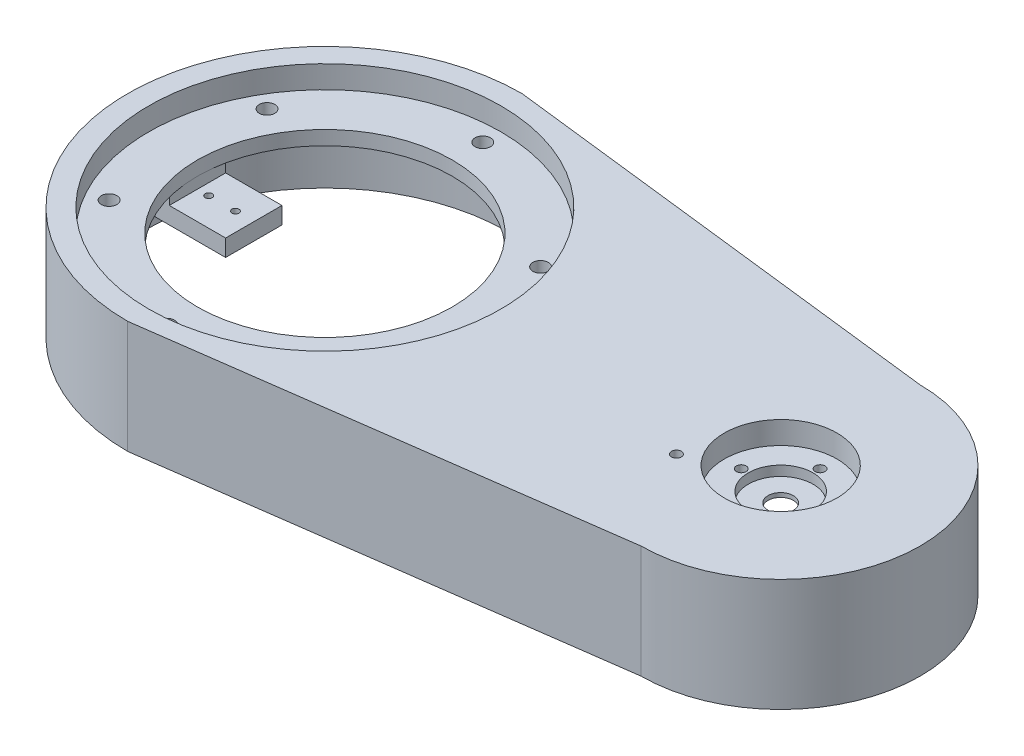
from build123d import *

# Parameters (mm, degrees)
BOSS_EXTRUDE1_DEPTH = 40
SKETCH2_R           = 45.22
SKETCH2_R_2         = 2.75
CUT_EXTRUDE1_DEPTH  = 28
SKETCH4_R           = 62.5
CUT_EXTRUDE2_DEPTH  = 8
CUT_EXTRUDE3_DEPTH  = 27
SKETCH6_R           = 1.75
SKETCH6_R_2         = 4.5
CUT_EXTRUDE4_DEPTH  = 23
SKETCH6_3_R         = 11.5
SKETCH6_3_R_2       = 4.5
CUT_EXTRUDE5_DEPTH  = 11.5
BOSS_EXTRUDE2_DEPTH = 10
SKETCH8_W           = 20
SKETCH8_H           = 6
BOSS_EXTRUDE3_DEPTH = 20
SKETCH9_R           = 1.25
CUT_EXTRUDE6_DEPTH  = 20
SKETCH6_4_R         = 20
SKETCH6_4_R_2       = 1.75
SKETCH6_4_R_3       = 4.5
CUT_EXTRUDE7_DEPTH  = 8
CUT_EXTRUDE8_START  = -168
SKETCH11_R          = 4.5
SKETCH11_R_2        = 1.75
CUT_EXTRUDE8_DEPTH  = 168


with BuildPart() as part:
    # Sketch1 → Boss-Extrude1 (new body)
    with BuildSketch(Plane(origin=(0, 0, 0), x_dir=(1, 0, 0), z_dir=(0, 1, 0))):
        with BuildLine():
            Line((0, 70), (160.2226, 51.102080384))
            ThreePointArc((160.2226, 51.102080384), (209.74985375, 1.574826635), (160.2226, -47.952427115))
            Line((160.2226, -47.952427115), (0, -70))
            ThreePointArc((0, -70), (-70, 0), (0, 70))
        make_face()
    extrude(amount=BOSS_EXTRUDE1_DEPTH)

    # Sketch2 → Cut-Extrude1 (cut)
    with BuildSketch(Plane(origin=(0, 40, 0), x_dir=(1, 0, 0), z_dir=(0, 1, 0))):
        Circle(SKETCH2_R)
        with Locations((0, 56.06)):
            Circle(SKETCH2_R_2)
        with Locations((-48.549384136, 28.03)):
            Circle(SKETCH2_R_2)
        with Locations((-48.549384136, -28.03)):
            Circle(SKETCH2_R_2)
        with Locations((0, -56.06)):
            Circle(SKETCH2_R_2)
        with Locations((48.549384136, -28.03)):
            Circle(SKETCH2_R_2)
        with Locations((48.549384136, 28.03)):
            Circle(SKETCH2_R_2)
    extrude(amount=-CUT_EXTRUDE1_DEPTH, mode=Mode.SUBTRACT)

    # Sketch4 → Cut-Extrude2 (cut)
    with BuildSketch(Plane(origin=(0, 40, 0), x_dir=(1, 0, 0), z_dir=(0, 1, 0))):
        Circle(SKETCH4_R)
    extrude(amount=-CUT_EXTRUDE2_DEPTH, mode=Mode.SUBTRACT)

    # Sketch5 → Cut-Extrude3 (cut)
    with BuildSketch(Plane.XZ):
        with BuildLine():
            Line((160.2226, 42.955173365), (0, 65))
            ThreePointArc((0, 65), (-65, 0), (0, -65))
            Line((0, -65), (160.2226, -46.104826635))
            ThreePointArc((160.2226, -46.104826635), (204.7526, -1.574826635), (160.2226, 42.955173365))
        make_face()
    extrude(amount=-CUT_EXTRUDE3_DEPTH, mode=Mode.SUBTRACT)

    # Sketch6 → Cut-Extrude4 (cut)
    with BuildSketch(Plane(origin=(0, 40, 0), x_dir=(1, 0, 0), z_dir=(0, 1, 0))):
        with Locations((174.2226, 1.574826635)):
            Circle(SKETCH6_R)
        with Locations((160.2226, 15.574826635)):
            Circle(SKETCH6_R)
        with Locations((160.2226, -12.425173365)):
            Circle(SKETCH6_R)
        with Locations((146.2226, 1.574826635)):
            Circle(SKETCH6_R)
        with Locations((160.2226, 1.574826635)):
            Circle(SKETCH6_R_2)
    extrude(amount=-CUT_EXTRUDE4_DEPTH, mode=Mode.SUBTRACT)

    # Sketch6_3 → Cut-Extrude5 (cut)
    with BuildSketch(Plane(origin=(0, 40, 0), x_dir=(1, 0, 0), z_dir=(0, 1, 0))):
        with Locations((160.2226, 1.574826635)):
            Circle(SKETCH6_3_R)
        with Locations((160.2226, 1.574826635)):
            Circle(SKETCH6_3_R_2, mode=Mode.SUBTRACT)
    extrude(amount=-CUT_EXTRUDE5_DEPTH, mode=Mode.SUBTRACT)

    # Sketch7 → Boss-Extrude2 (add)
    with BuildSketch(Plane.XZ.offset(-27)):
        Polygon((-45.22, 0), (-45.22, 10), (-50.22, 10), (-50.22, -10), (-45.22, -10), align=None)
    extrude(amount=BOSS_EXTRUDE2_DEPTH)

    # Sketch8 → Boss-Extrude3 (add)
    with BuildSketch(Plane(origin=(-45.22, 0, 0), x_dir=(0, 0, -1), z_dir=(1, 0, 0))):
        with Locations((0, 20)):
            Rectangle(SKETCH8_W, SKETCH8_H)
    extrude(amount=BOSS_EXTRUDE3_DEPTH)

    # Sketch9 → Cut-Extrude6 (cut)
    with BuildSketch(Plane.XZ.offset(-17)):
        with Locations((-31.72, 0)):
            Circle(SKETCH9_R)
        with Locations((-41.22, 0)):
            Circle(SKETCH9_R)
    extrude(amount=-CUT_EXTRUDE6_DEPTH, mode=Mode.SUBTRACT)

    # Sketch6_4 → Cut-Extrude7 (cut)
    with BuildSketch(Plane(origin=(0, 40, 0), x_dir=(1, 0, 0), z_dir=(0, 1, 0))):
        with Locations((160.2226, 1.574826635)):
            Circle(SKETCH6_4_R)
        with Locations((174.2226, 1.574826635)):
            Circle(SKETCH6_4_R_2, mode=Mode.SUBTRACT)
        with Locations((160.2226, -12.425173365)):
            Circle(SKETCH6_4_R_2, mode=Mode.SUBTRACT)
        with Locations((146.2226, 1.574826635)):
            Circle(SKETCH6_4_R_2, mode=Mode.SUBTRACT)
        with Locations((160.2226, 15.574826635)):
            Circle(SKETCH6_4_R_2, mode=Mode.SUBTRACT)
        with Locations((160.2226, 1.574826635)):
            Circle(SKETCH6_4_R_3, mode=Mode.SUBTRACT)
    extrude(amount=-CUT_EXTRUDE7_DEPTH, mode=Mode.SUBTRACT)

    # Sketch11 → Cut-Extrude8 (cut)
    with BuildSketch(Plane.XZ.offset(-27).offset(CUT_EXTRUDE8_START)):
        with Locations((160.2226, -1.574826635)):
            Circle(SKETCH11_R)
        with Locations((138.2226, 13.425173365)):
            Circle(SKETCH11_R_2)
    extrude(amount=CUT_EXTRUDE8_DEPTH, mode=Mode.SUBTRACT)


solid = part.part
